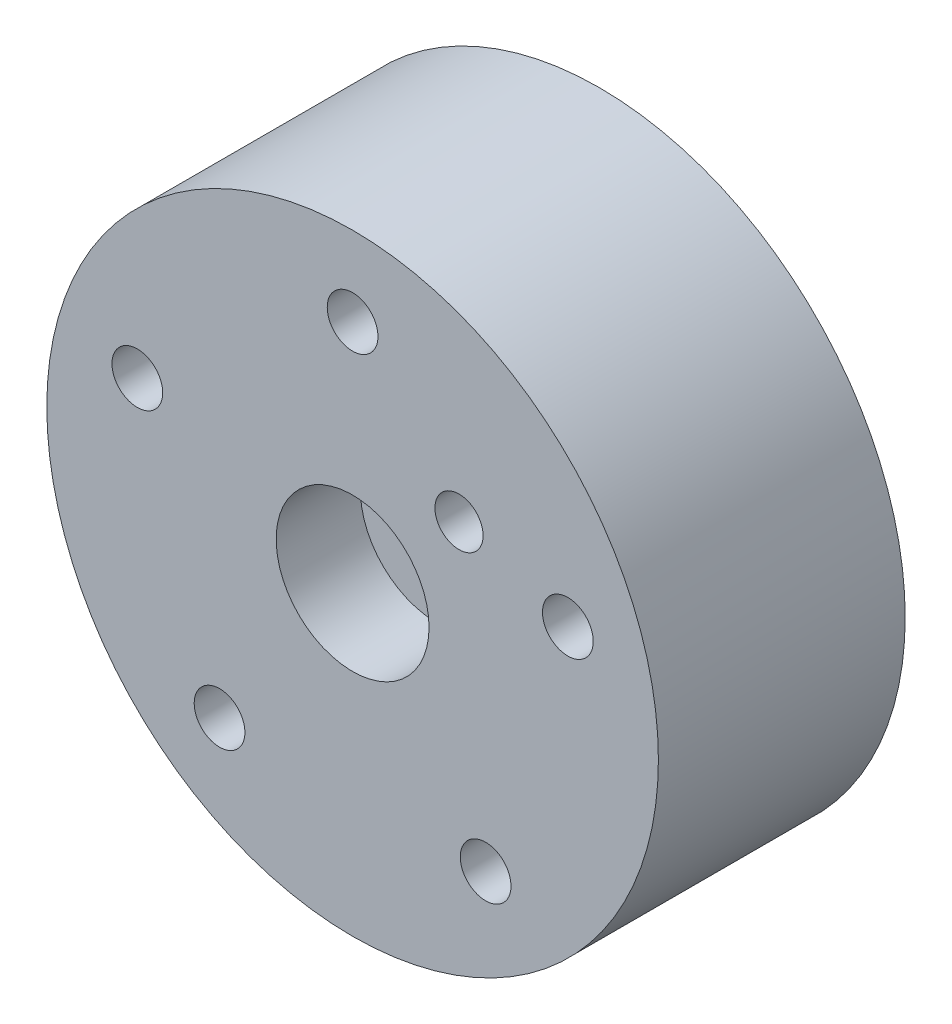
from build123d import *

# Parameters (mm, degrees)
SKETCH1_W           = 119
SKETCH1_H           = 114
BOSS_EXTRUDE1_DEPTH = 41
SKETCH4_R           = 4.214519236
CUT_EXTRUDE1_DEPTH  = 41
SKETCH7_R           = 7
CUT_EXTRUDE2_DEPTH  = 35
SKETCH8_R           = 4
CUT_EXTRUDE3_DEPTH  = 55
SKETCH9_R           = 12.7
CUT_EXTRUDE4_DEPTH  = 14
SKETCH10_OUTSIDE_W  = 154.964
SKETCH10_OUTSIDE_H  = 149.964
SKETCH10_OUTSIDE_R  = 50.8
CUT_EXTRUDE5_DEPTH  = 55


with BuildPart() as part:
    # Sketch1 → Boss-Extrude1 (new body)
    with BuildSketch(Plane.XY):
        Rectangle(SKETCH1_W, SKETCH1_H)
    extrude(amount=BOSS_EXTRUDE1_DEPTH)

    # Sketch4 → Cut-Extrude1 (cut)
    with BuildSketch(Plane(origin=(0, 0, 0), x_dir=(-1, 0, 0), z_dir=(0, 0, -1))):
        with Locations((0, 37.6)):
            Circle(SKETCH4_R)
        with Locations((35.759725013, 11.619038988)):
            Circle(SKETCH4_R)
        with Locations((22.100725486, -30.419038988)):
            Circle(SKETCH4_R)
        with Locations((-22.100725486, -30.419038988)):
            Circle(SKETCH4_R)
        with Locations((-35.759725013, 11.619038988)):
            Circle(SKETCH4_R)
    extrude(amount=-CUT_EXTRUDE1_DEPTH, mode=Mode.SUBTRACT)

    # Sketch7 → Cut-Extrude2 (cut)
    with BuildSketch(Plane(origin=(0, 0, 0), x_dir=(-1, 0, 0), z_dir=(0, 0, -1))):
        with Locations((0, 37.6)):
            Circle(SKETCH7_R)
        with Locations((35.759725013, 11.619038988)):
            Circle(SKETCH7_R)
        with Locations((22.100725486, -30.419038988)):
            Circle(SKETCH7_R)
        with Locations((-22.100725486, -30.419038988)):
            Circle(SKETCH7_R)
        with Locations((-35.759725013, 11.619038988)):
            Circle(SKETCH7_R)
    extrude(amount=-CUT_EXTRUDE2_DEPTH, mode=Mode.SUBTRACT)

    # Sketch8 → Cut-Extrude3 (cut)
    with BuildSketch(Plane(origin=(0, 0, 0), x_dir=(-1, 0, 0), z_dir=(0, 0, -1))):
        with Locations((-17.67766953, 17.67766953)):
            Circle(SKETCH8_R)
    extrude(amount=-CUT_EXTRUDE3_DEPTH, mode=Mode.SUBTRACT)

    # Sketch9 → Cut-Extrude4 (cut)
    with BuildSketch(Plane.XY.offset(41)):
        Circle(SKETCH9_R)
    extrude(amount=-CUT_EXTRUDE4_DEPTH, mode=Mode.SUBTRACT)

    # Sketch10 outside → Cut-Extrude5 (cut)
    with BuildSketch(Plane(origin=(0, 0, 0), x_dir=(-1, 0, 0), z_dir=(0, 0, -1))):
        Rectangle(SKETCH10_OUTSIDE_W, SKETCH10_OUTSIDE_H)
        Circle(SKETCH10_OUTSIDE_R, mode=Mode.SUBTRACT)
    extrude(amount=-CUT_EXTRUDE5_DEPTH, mode=Mode.SUBTRACT)


solid = part.part
